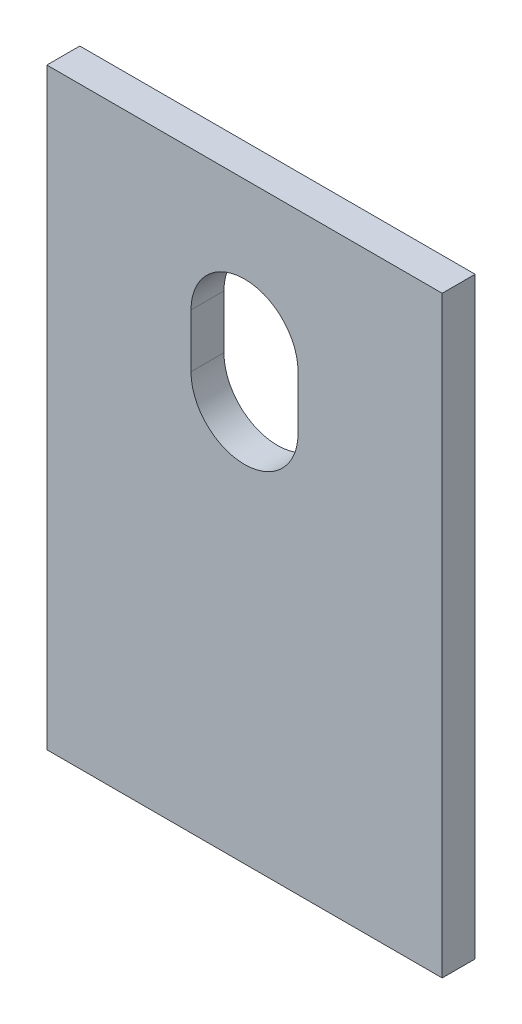
from build123d import *

# Parameters (mm, degrees)
SKETCH1_W           = 76.2
SKETCH1_H           = 6.35
BOSS_EXTRUDE1_DEPTH = 114.3
CUT_EXTRUDE1_DEPTH  = 7.35


with BuildPart() as part:
    # Sketch1 → Boss-Extrude1 (new body)
    with BuildSketch(Plane(origin=(0, 0, 0), x_dir=(1, 0, 0), z_dir=(0, 1, 0))):
        with Locations((38.1, 3.175)):
            Rectangle(SKETCH1_W, SKETCH1_H)
    extrude(amount=BOSS_EXTRUDE1_DEPTH)

    # Sketch2 → Cut-Extrude1 (cut, through all)
    with BuildSketch(Plane.XY):
        with BuildLine():
            Line((48.41875, 87.3125), (48.41875, 76.99375))
            ThreePointArc((48.41875, 76.99375), (38.1, 66.675), (27.78125, 76.99375))
            Line((27.78125, 76.99375), (27.78125, 87.3125))
            ThreePointArc((27.78125, 87.3125), (38.1, 97.63125), (48.41875, 87.3125))
        make_face()
    extrude(amount=-CUT_EXTRUDE1_DEPTH, mode=Mode.SUBTRACT)


solid = part.part
